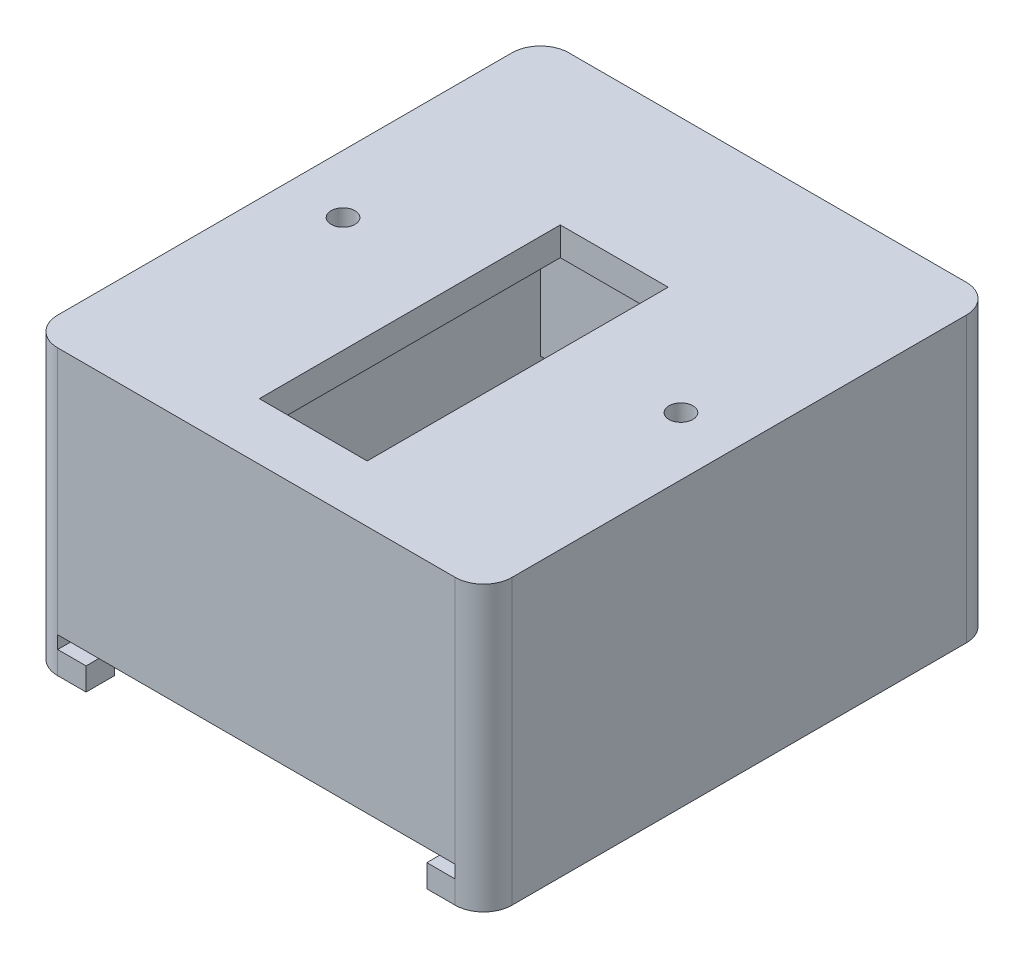
from build123d import *

# Parameters (mm, degrees)
SKETCH1_W           = 80
SKETCH1_H           = 90
SKETCH1_R           = 2.1
SKETCH1_W_2         = 19
SKETCH1_H_2         = 53
BOSS_EXTRUDE3_DEPTH = 50
SKETCH5_W           = 70
SKETCH5_H           = 80
CUT_EXTRUDE2_DEPTH  = 45
SKETCH6_R           = 2.5
CUT_EXTRUDE5_DEPTH  = 10.25
CUT_EXTRUDE6_DEPTH  = 10.25
FILLET2_R           = 5
CUT_EXTRUDE9_DEPTH  = 1000


with BuildPart() as part:
    # Sketch1 → Boss-Extrude3 (new body)
    with BuildSketch(Plane(origin=(0, 0, 0), x_dir=(1, 0, 0), z_dir=(0, 1, 0))):
        Rectangle(SKETCH1_W, SKETCH1_H)
        with Locations((29.75, 0)):
            Circle(SKETCH1_R, mode=Mode.SUBTRACT)
        with Locations((-29.75, 0)):
            Circle(SKETCH1_R, mode=Mode.SUBTRACT)
        with Locations((0, -8.5)):
            Rectangle(SKETCH1_W_2, SKETCH1_H_2, mode=Mode.SUBTRACT)
    extrude(amount=BOSS_EXTRUDE3_DEPTH)

    # Sketch5 → Cut-Extrude2 (cut)
    with BuildSketch(Plane(origin=(0, 0, 0), x_dir=(-1, 0, 0), z_dir=(0, -1, 0))):
        Rectangle(SKETCH5_W, SKETCH5_H)
    extrude(amount=-CUT_EXTRUDE2_DEPTH, mode=Mode.SUBTRACT)

    # Sketch6 → Cut-Extrude5 (cut)
    with BuildSketch(Plane(origin=(0, 0, -45), x_dir=(-1, 0, 0), z_dir=(0, 0, -1))):
        with Locations((-5, 40)):
            Circle(SKETCH6_R)
        with Locations((5, 40)):
            Circle(SKETCH6_R)
    extrude(amount=-CUT_EXTRUDE5_DEPTH, mode=Mode.SUBTRACT)

    # Sketch7 → Cut-Extrude6 (cut)
    with BuildSketch(Plane.ZY.offset(40)):
        Polygon((-26.375644347, 31), (-22.334192463, 38), (-26.375644347, 45), (-34.458548116, 45), (-38.5, 38), (-34.458548116, 31), align=None)
        Polygon((34.458548116, 31), (26.375644347, 31), (22.334192463, 38), (26.375644347, 45), (34.458548116, 45), (38.5, 38), align=None)
    extrude(amount=-CUT_EXTRUDE6_DEPTH, mode=Mode.SUBTRACT)

    # Fillet2
    fillet2_edges = [part.edges().sort_by_distance(p)[0] for p in [
        (40, 25, 45),
        (-40, 25, 45),
        (-40, 25, -45),
        (40, 25, -45),
    ]]
    fillet(fillet2_edges, radius=FILLET2_R)

    # Sketch8 → Cut-Extrude9 (cut)
    with BuildSketch(Plane.XY.offset(45)):
        Polygon((-35, 6.24869217), (35, 6.24869217), (35, 4), (30, 4), (30, 0), (-30, 0), (-30, 4), (-35, 4), align=None)
    extrude(amount=-CUT_EXTRUDE9_DEPTH, mode=Mode.SUBTRACT)


solid = part.part
